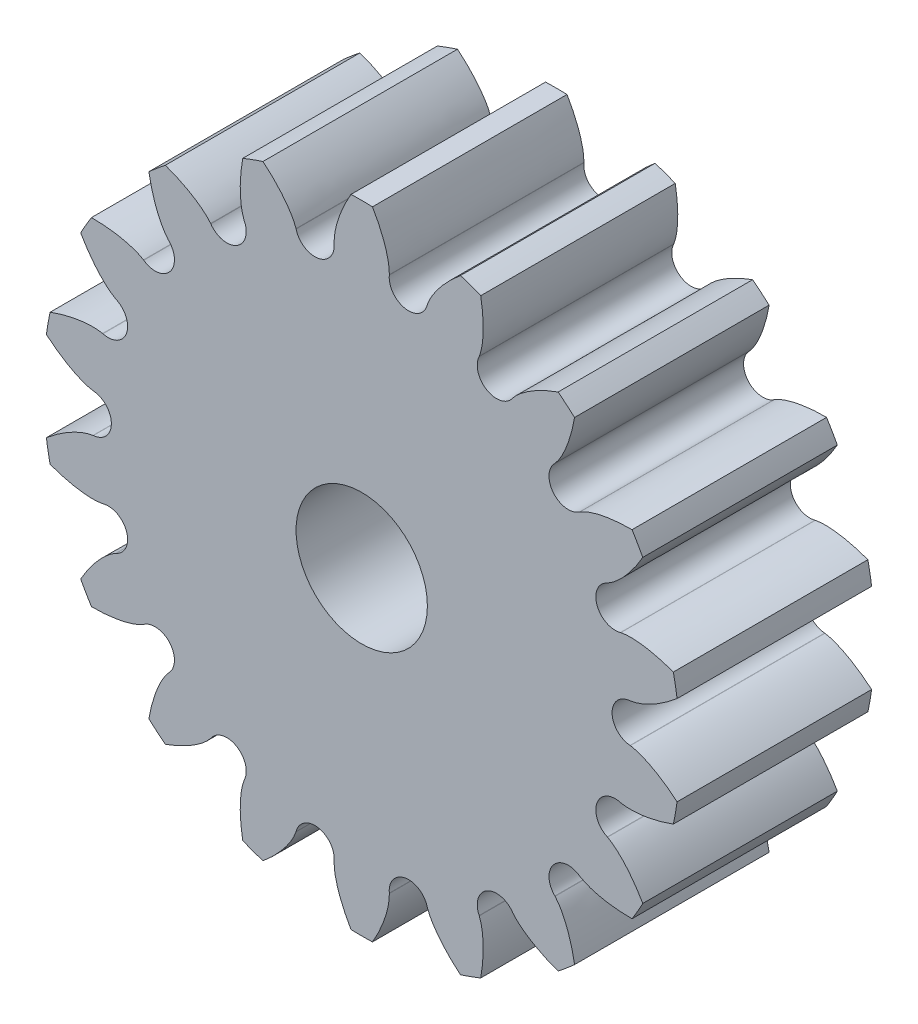
from build123d import *

# Parameters (mm, degrees)
SKETCH3_R                      = 3.8735
SKETCH3_R_2                    = 1.016
BASE_DEPTH                     = 3.0099
HALF_TOOTH_DEPTH               = 3.0099
PATTERN_OF_TOOTH_COUNT         = 18
PATTERN_OF_TOOTH_COPY_1_DEPTH  = 3.0099
PATTERN_OF_TOOTH_COPY_2_DEPTH  = 3.0099
PATTERN_OF_TOOTH_COPY_3_DEPTH  = 3.0099
PATTERN_OF_TOOTH_COPY_4_DEPTH  = 3.0099
PATTERN_OF_TOOTH_COPY_5_DEPTH  = 3.0099
PATTERN_OF_TOOTH_COPY_6_DEPTH  = 3.0099
PATTERN_OF_TOOTH_COPY_7_DEPTH  = 3.0099
PATTERN_OF_TOOTH_COPY_8_DEPTH  = 3.0099
PATTERN_OF_TOOTH_COPY_9_DEPTH  = 3.0099
PATTERN_OF_TOOTH_COPY_10_DEPTH = 3.0099
PATTERN_OF_TOOTH_COPY_11_DEPTH = 3.0099
PATTERN_OF_TOOTH_COPY_12_DEPTH = 3.0099
PATTERN_OF_TOOTH_COPY_13_DEPTH = 3.0099
PATTERN_OF_TOOTH_COPY_14_DEPTH = 3.0099
PATTERN_OF_TOOTH_COPY_15_DEPTH = 3.0099
PATTERN_OF_TOOTH_COPY_16_DEPTH = 3.0099
PATTERN_OF_TOOTH_COPY_17_DEPTH = 3.0099


with BuildPart() as part:
    # Sketch3 → Base (new body)
    with BuildSketch(Plane.XY):
        Circle(SKETCH3_R)
        Circle(SKETCH3_R_2, mode=Mode.SUBTRACT)
    extrude(amount=BASE_DEPTH)

    # Sketch2 → Half tooth (add)
    with BuildSketch(Plane.XY):
        with BuildLine():
            Line((0, 4.9276), (0, 3.8735))
            ThreePointArc((0, 3.8735), (0.33759777, 3.858760163), (0.672626216, 3.814652831))
            ThreePointArc((0.672626216, 3.814652831), (0.485562779, 3.929154116), (0.426627171, 4.14041194))
            Line((0.426627171, 4.14041194), (0.427145061, 4.145438058))
            add(Edge.make_bspline(
                [(0.166315357, 4.924792479), (0.258862053, 4.766378262), (0.375827452, 4.512802123), (0.428422138, 4.238585306), (0.427145061, 4.145438058)],
                knots=[0, 0, 0, 0, 0.664051884, 1, 1, 1, 1], degree=3))
            ThreePointArc((0.166315357, 4.924792479), (0.083169526, 4.92689807), (0, 4.9276))
        make_face()
    half_tooth = extrude(amount=HALF_TOOTH_DEPTH)

    # Mirror of half tooth: Half tooth across plane
    add(half_tooth.mirror(Plane.ZY))

    # Pattern of tooth: Half tooth ×18 about axis
    pattern_of_tooth_axis = Axis((0, 0, 3.0099), (0, 0, 1))
    for i in range(1, PATTERN_OF_TOOTH_COUNT):
        add(half_tooth.rotate(pattern_of_tooth_axis, i * 360 / PATTERN_OF_TOOTH_COUNT))

    # Pattern of tooth copy 1 sketch → Pattern of tooth copy 1 (add)
    with BuildSketch(Plane(origin=(0, 0, 0), x_dir=(-0.939692621, -0.342020143, 0), z_dir=(0, 0, 1))):
        with BuildLine():
            Line((0, -4.9276), (0, -3.8735))
            ThreePointArc((0, -3.8735), (0.33759777, -3.858760163), (0.672626216, -3.814652831))
            ThreePointArc((0.672626216, -3.814652831), (0.485562779, -3.929154116), (0.426627171, -4.14041194))
            Line((0.426627171, -4.14041194), (0.427145061, -4.145438058))
            add(Edge.make_bspline(
                [(0.166315357, -4.924792479), (0.258862053, -4.766378262), (0.375827452, -4.512802123), (0.428422138, -4.238585306), (0.427145061, -4.145438058)],
                knots=[0, 0, 0, 0, 0.664051884, 1, 1, 1, 1], degree=3))
            ThreePointArc((0.166315357, -4.924792479), (0.083169526, -4.92689807), (0, -4.9276))
        make_face()
    extrude(amount=PATTERN_OF_TOOTH_COPY_1_DEPTH)

    # Pattern of tooth copy 2 sketch → Pattern of tooth copy 2 (add)
    with BuildSketch(Plane(origin=(0, 0, 0), x_dir=(-0.766044443, -0.64278761, 0), z_dir=(0, 0, 1))):
        with BuildLine():
            Line((0, -4.9276), (0, -3.8735))
            ThreePointArc((0, -3.8735), (0.33759777, -3.858760163), (0.672626216, -3.814652831))
            ThreePointArc((0.672626216, -3.814652831), (0.485562779, -3.929154116), (0.426627171, -4.14041194))
            Line((0.426627171, -4.14041194), (0.427145061, -4.145438058))
            add(Edge.make_bspline(
                [(0.166315357, -4.924792479), (0.258862053, -4.766378262), (0.375827452, -4.512802123), (0.428422138, -4.238585306), (0.427145061, -4.145438058)],
                knots=[0, 0, 0, 0, 0.664051884, 1, 1, 1, 1], degree=3))
            ThreePointArc((0.166315357, -4.924792479), (0.083169526, -4.92689807), (0, -4.9276))
        make_face()
    extrude(amount=PATTERN_OF_TOOTH_COPY_2_DEPTH)

    # Pattern of tooth copy 3 sketch → Pattern of tooth copy 3 (add)
    with BuildSketch(Plane(origin=(0, 0, 0), x_dir=(-0.5, -0.866025404, 0), z_dir=(0, 0, 1))):
        with BuildLine():
            Line((0, -4.9276), (0, -3.8735))
            ThreePointArc((0, -3.8735), (0.33759777, -3.858760163), (0.672626216, -3.814652831))
            ThreePointArc((0.672626216, -3.814652831), (0.485562779, -3.929154116), (0.426627171, -4.14041194))
            Line((0.426627171, -4.14041194), (0.427145061, -4.145438058))
            add(Edge.make_bspline(
                [(0.166315357, -4.924792479), (0.258862053, -4.766378262), (0.375827452, -4.512802123), (0.428422138, -4.238585306), (0.427145061, -4.145438058)],
                knots=[0, 0, 0, 0, 0.664051884, 1, 1, 1, 1], degree=3))
            ThreePointArc((0.166315357, -4.924792479), (0.083169526, -4.92689807), (0, -4.9276))
        make_face()
    extrude(amount=PATTERN_OF_TOOTH_COPY_3_DEPTH)

    # Pattern of tooth copy 4 sketch → Pattern of tooth copy 4 (add)
    with BuildSketch(Plane(origin=(0, 0, 0), x_dir=(-0.173648178, -0.984807753, 0), z_dir=(0, 0, 1))):
        with BuildLine():
            Line((0, -4.9276), (0, -3.8735))
            ThreePointArc((0, -3.8735), (0.33759777, -3.858760163), (0.672626216, -3.814652831))
            ThreePointArc((0.672626216, -3.814652831), (0.485562779, -3.929154116), (0.426627171, -4.14041194))
            Line((0.426627171, -4.14041194), (0.427145061, -4.145438058))
            add(Edge.make_bspline(
                [(0.166315357, -4.924792479), (0.258862053, -4.766378262), (0.375827452, -4.512802123), (0.428422138, -4.238585306), (0.427145061, -4.145438058)],
                knots=[0, 0, 0, 0, 0.664051884, 1, 1, 1, 1], degree=3))
            ThreePointArc((0.166315357, -4.924792479), (0.083169526, -4.92689807), (0, -4.9276))
        make_face()
    extrude(amount=PATTERN_OF_TOOTH_COPY_4_DEPTH)

    # Pattern of tooth copy 5 sketch → Pattern of tooth copy 5 (add)
    with BuildSketch(Plane(origin=(0, 0, 0), x_dir=(0.173648178, -0.984807753, 0), z_dir=(0, 0, 1))):
        with BuildLine():
            Line((0, -4.9276), (0, -3.8735))
            ThreePointArc((0, -3.8735), (0.33759777, -3.858760163), (0.672626216, -3.814652831))
            ThreePointArc((0.672626216, -3.814652831), (0.485562779, -3.929154116), (0.426627171, -4.14041194))
            Line((0.426627171, -4.14041194), (0.427145061, -4.145438058))
            add(Edge.make_bspline(
                [(0.166315357, -4.924792479), (0.258862053, -4.766378262), (0.375827452, -4.512802123), (0.428422138, -4.238585306), (0.427145061, -4.145438058)],
                knots=[0, 0, 0, 0, 0.664051884, 1, 1, 1, 1], degree=3))
            ThreePointArc((0.166315357, -4.924792479), (0.083169526, -4.92689807), (0, -4.9276))
        make_face()
    extrude(amount=PATTERN_OF_TOOTH_COPY_5_DEPTH)

    # Pattern of tooth copy 6 sketch → Pattern of tooth copy 6 (add)
    with BuildSketch(Plane(origin=(0, 0, 0), x_dir=(0.5, -0.866025404, 0), z_dir=(0, 0, 1))):
        with BuildLine():
            Line((0, -4.9276), (0, -3.8735))
            ThreePointArc((0, -3.8735), (0.33759777, -3.858760163), (0.672626216, -3.814652831))
            ThreePointArc((0.672626216, -3.814652831), (0.485562779, -3.929154116), (0.426627171, -4.14041194))
            Line((0.426627171, -4.14041194), (0.427145061, -4.145438058))
            add(Edge.make_bspline(
                [(0.166315357, -4.924792479), (0.258862053, -4.766378262), (0.375827452, -4.512802123), (0.428422138, -4.238585306), (0.427145061, -4.145438058)],
                knots=[0, 0, 0, 0, 0.664051884, 1, 1, 1, 1], degree=3))
            ThreePointArc((0.166315357, -4.924792479), (0.083169526, -4.92689807), (0, -4.9276))
        make_face()
    extrude(amount=PATTERN_OF_TOOTH_COPY_6_DEPTH)

    # Pattern of tooth copy 7 sketch → Pattern of tooth copy 7 (add)
    with BuildSketch(Plane(origin=(0, 0, 0), x_dir=(0.766044443, -0.64278761, 0), z_dir=(0, 0, 1))):
        with BuildLine():
            Line((0, -4.9276), (0, -3.8735))
            ThreePointArc((0, -3.8735), (0.33759777, -3.858760163), (0.672626216, -3.814652831))
            ThreePointArc((0.672626216, -3.814652831), (0.485562779, -3.929154116), (0.426627171, -4.14041194))
            Line((0.426627171, -4.14041194), (0.427145061, -4.145438058))
            add(Edge.make_bspline(
                [(0.166315357, -4.924792479), (0.258862053, -4.766378262), (0.375827452, -4.512802123), (0.428422138, -4.238585306), (0.427145061, -4.145438058)],
                knots=[0, 0, 0, 0, 0.664051884, 1, 1, 1, 1], degree=3))
            ThreePointArc((0.166315357, -4.924792479), (0.083169526, -4.92689807), (0, -4.9276))
        make_face()
    extrude(amount=PATTERN_OF_TOOTH_COPY_7_DEPTH)

    # Pattern of tooth copy 8 sketch → Pattern of tooth copy 8 (add)
    with BuildSketch(Plane(origin=(0, 0, 0), x_dir=(0.939692621, -0.342020143, 0), z_dir=(0, 0, 1))):
        with BuildLine():
            Line((0, -4.9276), (0, -3.8735))
            ThreePointArc((0, -3.8735), (0.33759777, -3.858760163), (0.672626216, -3.814652831))
            ThreePointArc((0.672626216, -3.814652831), (0.485562779, -3.929154116), (0.426627171, -4.14041194))
            Line((0.426627171, -4.14041194), (0.427145061, -4.145438058))
            add(Edge.make_bspline(
                [(0.166315357, -4.924792479), (0.258862053, -4.766378262), (0.375827452, -4.512802123), (0.428422138, -4.238585306), (0.427145061, -4.145438058)],
                knots=[0, 0, 0, 0, 0.664051884, 1, 1, 1, 1], degree=3))
            ThreePointArc((0.166315357, -4.924792479), (0.083169526, -4.92689807), (0, -4.9276))
        make_face()
    extrude(amount=PATTERN_OF_TOOTH_COPY_8_DEPTH)

    # Pattern of tooth copy 9 sketch → Pattern of tooth copy 9 (add)
    with BuildSketch(Plane.XY):
        with BuildLine():
            Line((0, -4.9276), (0, -3.8735))
            ThreePointArc((0, -3.8735), (0.33759777, -3.858760163), (0.672626216, -3.814652831))
            ThreePointArc((0.672626216, -3.814652831), (0.485562779, -3.929154116), (0.426627171, -4.14041194))
            Line((0.426627171, -4.14041194), (0.427145061, -4.145438058))
            add(Edge.make_bspline(
                [(0.166315357, -4.924792479), (0.258862053, -4.766378262), (0.375827452, -4.512802123), (0.428422138, -4.238585306), (0.427145061, -4.145438058)],
                knots=[0, 0, 0, 0, 0.664051884, 1, 1, 1, 1], degree=3))
            ThreePointArc((0.166315357, -4.924792479), (0.083169526, -4.92689807), (0, -4.9276))
        make_face()
    extrude(amount=PATTERN_OF_TOOTH_COPY_9_DEPTH)

    # Pattern of tooth copy 10 sketch → Pattern of tooth copy 10 (add)
    with BuildSketch(Plane(origin=(0, 0, 0), x_dir=(0.939692621, 0.342020143, 0), z_dir=(0, 0, 1))):
        with BuildLine():
            Line((0, -4.9276), (0, -3.8735))
            ThreePointArc((0, -3.8735), (0.33759777, -3.858760163), (0.672626216, -3.814652831))
            ThreePointArc((0.672626216, -3.814652831), (0.485562779, -3.929154116), (0.426627171, -4.14041194))
            Line((0.426627171, -4.14041194), (0.427145061, -4.145438058))
            add(Edge.make_bspline(
                [(0.166315357, -4.924792479), (0.258862053, -4.766378262), (0.375827452, -4.512802123), (0.428422138, -4.238585306), (0.427145061, -4.145438058)],
                knots=[0, 0, 0, 0, 0.664051884, 1, 1, 1, 1], degree=3))
            ThreePointArc((0.166315357, -4.924792479), (0.083169526, -4.92689807), (0, -4.9276))
        make_face()
    extrude(amount=PATTERN_OF_TOOTH_COPY_10_DEPTH)

    # Pattern of tooth copy 11 sketch → Pattern of tooth copy 11 (add)
    with BuildSketch(Plane(origin=(0, 0, 0), x_dir=(0.766044443, 0.64278761, 0), z_dir=(0, 0, 1))):
        with BuildLine():
            Line((0, -4.9276), (0, -3.8735))
            ThreePointArc((0, -3.8735), (0.33759777, -3.858760163), (0.672626216, -3.814652831))
            ThreePointArc((0.672626216, -3.814652831), (0.485562779, -3.929154116), (0.426627171, -4.14041194))
            Line((0.426627171, -4.14041194), (0.427145061, -4.145438058))
            add(Edge.make_bspline(
                [(0.166315357, -4.924792479), (0.258862053, -4.766378262), (0.375827452, -4.512802123), (0.428422138, -4.238585306), (0.427145061, -4.145438058)],
                knots=[0, 0, 0, 0, 0.664051884, 1, 1, 1, 1], degree=3))
            ThreePointArc((0.166315357, -4.924792479), (0.083169526, -4.92689807), (0, -4.9276))
        make_face()
    extrude(amount=PATTERN_OF_TOOTH_COPY_11_DEPTH)

    # Pattern of tooth copy 12 sketch → Pattern of tooth copy 12 (add)
    with BuildSketch(Plane(origin=(0, 0, 0), x_dir=(0.5, 0.866025404, 0), z_dir=(0, 0, 1))):
        with BuildLine():
            Line((0, -4.9276), (0, -3.8735))
            ThreePointArc((0, -3.8735), (0.33759777, -3.858760163), (0.672626216, -3.814652831))
            ThreePointArc((0.672626216, -3.814652831), (0.485562779, -3.929154116), (0.426627171, -4.14041194))
            Line((0.426627171, -4.14041194), (0.427145061, -4.145438058))
            add(Edge.make_bspline(
                [(0.166315357, -4.924792479), (0.258862053, -4.766378262), (0.375827452, -4.512802123), (0.428422138, -4.238585306), (0.427145061, -4.145438058)],
                knots=[0, 0, 0, 0, 0.664051884, 1, 1, 1, 1], degree=3))
            ThreePointArc((0.166315357, -4.924792479), (0.083169526, -4.92689807), (0, -4.9276))
        make_face()
    extrude(amount=PATTERN_OF_TOOTH_COPY_12_DEPTH)

    # Pattern of tooth copy 13 sketch → Pattern of tooth copy 13 (add)
    with BuildSketch(Plane(origin=(0, 0, 0), x_dir=(0.173648178, 0.984807753, 0), z_dir=(0, 0, 1))):
        with BuildLine():
            Line((0, -4.9276), (0, -3.8735))
            ThreePointArc((0, -3.8735), (0.33759777, -3.858760163), (0.672626216, -3.814652831))
            ThreePointArc((0.672626216, -3.814652831), (0.485562779, -3.929154116), (0.426627171, -4.14041194))
            Line((0.426627171, -4.14041194), (0.427145061, -4.145438058))
            add(Edge.make_bspline(
                [(0.166315357, -4.924792479), (0.258862053, -4.766378262), (0.375827452, -4.512802123), (0.428422138, -4.238585306), (0.427145061, -4.145438058)],
                knots=[0, 0, 0, 0, 0.664051884, 1, 1, 1, 1], degree=3))
            ThreePointArc((0.166315357, -4.924792479), (0.083169526, -4.92689807), (0, -4.9276))
        make_face()
    extrude(amount=PATTERN_OF_TOOTH_COPY_13_DEPTH)

    # Pattern of tooth copy 14 sketch → Pattern of tooth copy 14 (add)
    with BuildSketch(Plane(origin=(0, 0, 0), x_dir=(-0.173648178, 0.984807753, 0), z_dir=(0, 0, 1))):
        with BuildLine():
            Line((0, -4.9276), (0, -3.8735))
            ThreePointArc((0, -3.8735), (0.33759777, -3.858760163), (0.672626216, -3.814652831))
            ThreePointArc((0.672626216, -3.814652831), (0.485562779, -3.929154116), (0.426627171, -4.14041194))
            Line((0.426627171, -4.14041194), (0.427145061, -4.145438058))
            add(Edge.make_bspline(
                [(0.166315357, -4.924792479), (0.258862053, -4.766378262), (0.375827452, -4.512802123), (0.428422138, -4.238585306), (0.427145061, -4.145438058)],
                knots=[0, 0, 0, 0, 0.664051884, 1, 1, 1, 1], degree=3))
            ThreePointArc((0.166315357, -4.924792479), (0.083169526, -4.92689807), (0, -4.9276))
        make_face()
    extrude(amount=PATTERN_OF_TOOTH_COPY_14_DEPTH)

    # Pattern of tooth copy 15 sketch → Pattern of tooth copy 15 (add)
    with BuildSketch(Plane(origin=(0, 0, 0), x_dir=(-0.5, 0.866025404, 0), z_dir=(0, 0, 1))):
        with BuildLine():
            Line((0, -4.9276), (0, -3.8735))
            ThreePointArc((0, -3.8735), (0.33759777, -3.858760163), (0.672626216, -3.814652831))
            ThreePointArc((0.672626216, -3.814652831), (0.485562779, -3.929154116), (0.426627171, -4.14041194))
            Line((0.426627171, -4.14041194), (0.427145061, -4.145438058))
            add(Edge.make_bspline(
                [(0.166315357, -4.924792479), (0.258862053, -4.766378262), (0.375827452, -4.512802123), (0.428422138, -4.238585306), (0.427145061, -4.145438058)],
                knots=[0, 0, 0, 0, 0.664051884, 1, 1, 1, 1], degree=3))
            ThreePointArc((0.166315357, -4.924792479), (0.083169526, -4.92689807), (0, -4.9276))
        make_face()
    extrude(amount=PATTERN_OF_TOOTH_COPY_15_DEPTH)

    # Pattern of tooth copy 16 sketch → Pattern of tooth copy 16 (add)
    with BuildSketch(Plane(origin=(0, 0, 0), x_dir=(-0.766044443, 0.64278761, 0), z_dir=(0, 0, 1))):
        with BuildLine():
            Line((0, -4.9276), (0, -3.8735))
            ThreePointArc((0, -3.8735), (0.33759777, -3.858760163), (0.672626216, -3.814652831))
            ThreePointArc((0.672626216, -3.814652831), (0.485562779, -3.929154116), (0.426627171, -4.14041194))
            Line((0.426627171, -4.14041194), (0.427145061, -4.145438058))
            add(Edge.make_bspline(
                [(0.166315357, -4.924792479), (0.258862053, -4.766378262), (0.375827452, -4.512802123), (0.428422138, -4.238585306), (0.427145061, -4.145438058)],
                knots=[0, 0, 0, 0, 0.664051884, 1, 1, 1, 1], degree=3))
            ThreePointArc((0.166315357, -4.924792479), (0.083169526, -4.92689807), (0, -4.9276))
        make_face()
    extrude(amount=PATTERN_OF_TOOTH_COPY_16_DEPTH)

    # Pattern of tooth copy 17 sketch → Pattern of tooth copy 17 (add)
    with BuildSketch(Plane(origin=(0, 0, 0), x_dir=(-0.939692621, 0.342020143, 0), z_dir=(0, 0, 1))):
        with BuildLine():
            Line((0, -4.9276), (0, -3.8735))
            ThreePointArc((0, -3.8735), (0.33759777, -3.858760163), (0.672626216, -3.814652831))
            ThreePointArc((0.672626216, -3.814652831), (0.485562779, -3.929154116), (0.426627171, -4.14041194))
            Line((0.426627171, -4.14041194), (0.427145061, -4.145438058))
            add(Edge.make_bspline(
                [(0.166315357, -4.924792479), (0.258862053, -4.766378262), (0.375827452, -4.512802123), (0.428422138, -4.238585306), (0.427145061, -4.145438058)],
                knots=[0, 0, 0, 0, 0.664051884, 1, 1, 1, 1], degree=3))
            ThreePointArc((0.166315357, -4.924792479), (0.083169526, -4.92689807), (0, -4.9276))
        make_face()
    extrude(amount=PATTERN_OF_TOOTH_COPY_17_DEPTH)


solid = part.part
